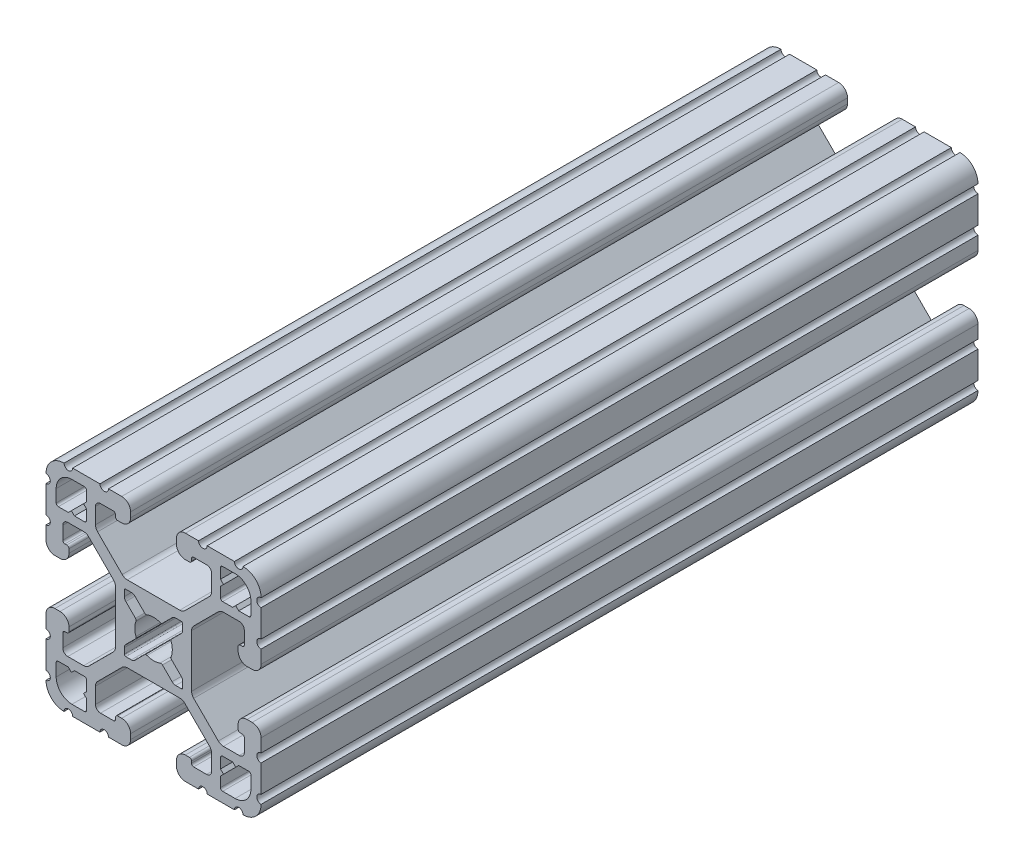
from build123d import *

# Parameters (mm, degrees)
BOSS_EXTRUDE1_DEPTH = 127


with BuildPart() as part:
    # Sketch1 → Boss-Extrude1 (new body)
    with BuildSketch(Plane(origin=(0, 0, -2322.576), x_dir=(-1, 0, 0), z_dir=(0, 0, -1))):
        with BuildLine():
            Line((19.05, -14.325600033), (19.05, -9.4996))
            ThreePointArc((19.05, -9.4996), (18.288, -8.7376), (19.05, -7.9756))
            Line((19.05, -7.9756), (19.05, -5.6388))
            ThreePointArc((19.05, -5.6388), (18.588751759, -4.525248241), (17.4752, -4.064))
            Line((17.4752, -4.064), (16.5608, -4.064))
            ThreePointArc((16.5608, -4.064), (15.447248241, -4.525248241), (14.986, -5.6388))
            Line((14.986, -5.6388), (14.986, -6.350014224))
            ThreePointArc((14.986, -6.350014224), (15.097592316, -6.619421908), (15.367, -6.731014224))
            Line((15.367, -6.731014224), (15.6972, -6.731014224))
            ThreePointArc((15.6972, -6.731014224), (15.966607684, -6.84260654), (16.0782, -7.112014224))
            Line((16.0782, -7.112014224), (16.0782, -9.398014224))
            ThreePointArc((16.0782, -9.398014224), (15.817817928, -10.026632152), (15.1892, -10.287014224))
            Line((15.1892, -10.287014224), (12.375630013, -10.287014224))
            ThreePointArc((12.375630013, -10.287014224), (11.889622054, -10.19034123), (11.477604401, -9.915039836))
            Line((11.477604401, -9.915039836), (7.115699788, -5.553135223))
            ThreePointArc((7.115699788, -5.553135223), (6.840398394, -5.14111757), (6.7437254, -4.655109611))
            Line((6.7437254, -4.655109611), (6.7437254, 4.655109611))
            ThreePointArc((6.7437254, 4.655109611), (6.840398394, 5.14111757), (7.115699788, 5.553135223))
            Line((7.115699788, 5.553135223), (11.477604401, 9.915039836))
            ThreePointArc((11.477604401, 9.915039836), (11.889622054, 10.19034123), (12.375630013, 10.287014224))
            Line((12.375630013, 10.287014224), (15.1892, 10.287014224))
            ThreePointArc((15.1892, 10.287014224), (15.817817928, 10.026632152), (16.0782, 9.398014224))
            Line((16.0782, 9.398014224), (16.0782, 7.112014224))
            ThreePointArc((16.0782, 7.112014224), (15.966607684, 6.84260654), (15.6972, 6.731014224))
            Line((15.6972, 6.731014224), (15.367, 6.731014224))
            ThreePointArc((15.367, 6.731014224), (15.097592316, 6.619421908), (14.986, 6.350014224))
            Line((14.986, 6.350014224), (14.986, 5.6388))
            ThreePointArc((14.986, 5.6388), (15.447248241, 4.525248241), (16.5608, 4.064))
            Line((16.5608, 4.064), (17.4752, 4.064))
            ThreePointArc((17.4752, 4.064), (18.588751759, 4.525248241), (19.05, 5.6388))
            Line((19.05, 5.6388), (19.05, 7.9756))
            ThreePointArc((19.05, 7.9756), (18.288, 8.7376), (19.05, 9.4996))
            Line((19.05, 9.4996), (19.05, 14.325599984))
            ThreePointArc((19.05, 14.325599984), (18.287999986, 15.087549208), (19.049898416, 15.849600009))
            ThreePointArc((19.049898416, 15.849600009), (18.120064036, 18.120064058), (15.849599977, 19.049898414))
            ThreePointArc((15.849599977, 19.049898414), (15.0875492, 18.288000035), (14.325600017, 19.050000016))
            Line((14.325600017, 19.050000016), (9.499600001, 19.050000016))
            ThreePointArc((9.499600001, 19.050000016), (8.737600001, 18.288000016), (7.975600001, 19.050000016))
            Line((7.975600001, 19.050000016), (5.638800016, 19.050000016))
            ThreePointArc((5.638800016, 19.050000016), (4.525248257, 18.588751775), (4.064000016, 17.475200016))
            Line((4.064000016, 17.475200016), (4.064000016, 16.5608))
            ThreePointArc((4.064000016, 16.5608), (4.525248257, 15.447248241), (5.638800016, 14.986))
            Line((5.638800016, 14.986), (6.350014224, 14.986))
            ThreePointArc((6.350014224, 14.986), (6.619421908, 15.097592316), (6.731014224, 15.367))
            Line((6.731014224, 15.367), (6.731014224, 15.6972))
            ThreePointArc((6.731014224, 15.6972), (6.84260654, 15.966607684), (7.112014224, 16.0782))
            Line((7.112014224, 16.0782), (9.398014224, 16.0782))
            ThreePointArc((9.398014224, 16.0782), (10.026632152, 15.817817928), (10.287014224, 15.1892))
            Line((10.287014224, 15.1892), (10.287014224, 12.375630013))
            ThreePointArc((10.287014224, 12.375630013), (10.19034123, 11.889622054), (9.915039836, 11.477604401))
            Line((9.915039836, 11.477604401), (5.553135223, 7.115699788))
            ThreePointArc((5.553135223, 7.115699788), (5.14111757, 6.840398394), (4.655109611, 6.7437254))
            Line((4.655109611, 6.7437254), (-4.655109611, 6.7437254))
            ThreePointArc((-4.655109611, 6.7437254), (-5.14111757, 6.840398394), (-5.553135223, 7.115699788))
            Line((-5.553135223, 7.115699788), (-9.915039836, 11.477604401))
            ThreePointArc((-9.915039836, 11.477604401), (-10.19034123, 11.889622054), (-10.287014224, 12.375630013))
            Line((-10.287014224, 12.375630013), (-10.287014224, 15.1892))
            ThreePointArc((-10.287014224, 15.1892), (-10.026632152, 15.817817928), (-9.398014224, 16.0782))
            Line((-9.398014224, 16.0782), (-7.112014224, 16.0782))
            ThreePointArc((-7.112014224, 16.0782), (-6.84260654, 15.966607684), (-6.731014224, 15.6972))
            Line((-6.731014224, 15.6972), (-6.731014224, 15.367))
            ThreePointArc((-6.731014224, 15.367), (-6.619421908, 15.097592316), (-6.350014224, 14.986))
            Line((-6.350014224, 14.986), (-5.638799984, 14.986))
            ThreePointArc((-5.638799984, 14.986), (-4.525248225, 15.447248241), (-4.063999984, 16.5608))
            Line((-4.063999984, 16.5608), (-4.063999984, 17.475200016))
            ThreePointArc((-4.063999984, 17.475200016), (-4.525248225, 18.588751775), (-5.638799984, 19.050000016))
            Line((-5.638799984, 19.050000016), (-7.975599999, 19.050000016))
            ThreePointArc((-7.975599999, 19.050000016), (-8.737599999, 18.288000016), (-9.499599999, 19.050000016))
            Line((-9.499599999, 19.050000016), (-14.325599999, 19.050000016))
            ThreePointArc((-14.325599999, 19.050000016), (-15.087549199, 18.288000018), (-15.849599993, 19.049898416))
            ThreePointArc((-15.849599993, 19.049898416), (-18.120064042, 18.120064036), (-19.049898398, 15.849599976))
            ThreePointArc((-19.049898398, 15.849599976), (-18.288000019, 15.087549199), (-19.05, 14.325600017))
            Line((-19.05, 14.325600017), (-19.05, 9.4996))
            ThreePointArc((-19.05, 9.4996), (-18.288, 8.7376), (-19.05, 7.9756))
            Line((-19.05, 7.9756), (-19.05, 5.6388))
            ThreePointArc((-19.05, 5.6388), (-18.588751759, 4.525248241), (-17.4752, 4.064))
            Line((-17.4752, 4.064), (-16.5608, 4.064))
            ThreePointArc((-16.5608, 4.064), (-15.447248241, 4.525248241), (-14.986, 5.6388))
            Line((-14.986, 5.6388), (-14.986, 6.350014224))
            ThreePointArc((-14.986, 6.350014224), (-15.097592316, 6.619421908), (-15.367, 6.731014224))
            Line((-15.367, 6.731014224), (-15.6972, 6.731014224))
            ThreePointArc((-15.6972, 6.731014224), (-15.966607684, 6.84260654), (-16.0782, 7.112014224))
            Line((-16.0782, 7.112014224), (-16.0782, 9.398014224))
            ThreePointArc((-16.0782, 9.398014224), (-15.817817928, 10.026632152), (-15.1892, 10.287014224))
            Line((-15.1892, 10.287014224), (-12.375630013, 10.287014224))
            ThreePointArc((-12.375630013, 10.287014224), (-11.889622054, 10.19034123), (-11.477604401, 9.915039836))
            Line((-11.477604401, 9.915039836), (-7.115699788, 5.553135223))
            ThreePointArc((-7.115699788, 5.553135223), (-6.840398394, 5.14111757), (-6.7437254, 4.655109611))
            Line((-6.7437254, 4.655109611), (-6.7437254, -4.655109611))
            ThreePointArc((-6.7437254, -4.655109611), (-6.840398394, -5.14111757), (-7.115699788, -5.553135223))
            Line((-7.115699788, -5.553135223), (-11.477604401, -9.915039836))
            ThreePointArc((-11.477604401, -9.915039836), (-11.889622054, -10.19034123), (-12.375630013, -10.287014224))
            Line((-12.375630013, -10.287014224), (-15.1892, -10.287014224))
            ThreePointArc((-15.1892, -10.287014224), (-15.817817928, -10.026632152), (-16.0782, -9.398014224))
            Line((-16.0782, -9.398014224), (-16.0782, -7.112014224))
            ThreePointArc((-16.0782, -7.112014224), (-15.966607684, -6.84260654), (-15.6972, -6.731014224))
            Line((-15.6972, -6.731014224), (-15.367, -6.731014224))
            ThreePointArc((-15.367, -6.731014224), (-15.097592316, -6.619421908), (-14.986, -6.350014224))
            Line((-14.986, -6.350014224), (-14.986, -5.6388))
            ThreePointArc((-14.986, -5.6388), (-15.447248241, -4.525248241), (-16.5608, -4.064))
            Line((-16.5608, -4.064), (-17.4752, -4.064))
            ThreePointArc((-17.4752, -4.064), (-18.588751759, -4.525248241), (-19.05, -5.6388))
            Line((-19.05, -5.6388), (-19.05, -7.9756))
            ThreePointArc((-19.05, -7.9756), (-18.288, -8.7376), (-19.05, -9.4996))
            Line((-19.05, -9.4996), (-19.05, -14.3256))
            ThreePointArc((-19.05, -14.3256), (-18.288000002, -15.0875492), (-19.0498984, -15.849599993))
            ThreePointArc((-19.0498984, -15.849599993), (-18.120064019, -18.120064043), (-15.84959996, -19.049898399))
            ThreePointArc((-15.84959996, -19.049898399), (-15.087549183, -18.288000019), (-14.325600001, -19.050000001))
            Line((-14.325600001, -19.050000001), (-9.499599984, -19.050000001))
            ThreePointArc((-9.499599984, -19.050000001), (-8.737599984, -18.288000001), (-7.975599984, -19.050000001))
            Line((-7.975599984, -19.050000001), (-5.638799984, -19.050000001))
            ThreePointArc((-5.638799984, -19.050000001), (-4.525248225, -18.58875176), (-4.063999984, -17.475200001))
            Line((-4.063999984, -17.475200001), (-4.063999984, -16.5608))
            ThreePointArc((-4.063999984, -16.5608), (-4.525248225, -15.447248241), (-5.638799984, -14.986))
            Line((-5.638799984, -14.986), (-6.350014224, -14.986))
            ThreePointArc((-6.350014224, -14.986), (-6.619421908, -15.097592316), (-6.731014224, -15.367))
            Line((-6.731014224, -15.367), (-6.731014224, -15.6972))
            ThreePointArc((-6.731014224, -15.6972), (-6.84260654, -15.966607684), (-7.112014224, -16.0782))
            Line((-7.112014224, -16.0782), (-9.398014224, -16.0782))
            ThreePointArc((-9.398014224, -16.0782), (-10.026632152, -15.817817928), (-10.287014224, -15.1892))
            Line((-10.287014224, -15.1892), (-10.287014224, -12.375630013))
            ThreePointArc((-10.287014224, -12.375630013), (-10.19034123, -11.889622054), (-9.915039836, -11.477604401))
            Line((-9.915039836, -11.477604401), (-5.553135223, -7.115699788))
            ThreePointArc((-5.553135223, -7.115699788), (-5.14111757, -6.840398394), (-4.655109611, -6.7437254))
            Line((-4.655109611, -6.7437254), (4.655109611, -6.7437254))
            ThreePointArc((4.655109611, -6.7437254), (5.14111757, -6.840398394), (5.553135223, -7.115699788))
            Line((5.553135223, -7.115699788), (9.915039836, -11.477604401))
            ThreePointArc((9.915039836, -11.477604401), (10.19034123, -11.889622054), (10.287014224, -12.375630013))
            Line((10.287014224, -12.375630013), (10.287014224, -15.1892))
            ThreePointArc((10.287014224, -15.1892), (10.026632152, -15.817817928), (9.398014224, -16.0782))
            Line((9.398014224, -16.0782), (7.112014224, -16.0782))
            ThreePointArc((7.112014224, -16.0782), (6.84260654, -15.966607684), (6.731014224, -15.6972))
            Line((6.731014224, -15.6972), (6.731014224, -15.367))
            ThreePointArc((6.731014224, -15.367), (6.619421908, -15.097592316), (6.350014224, -14.986))
            Line((6.350014224, -14.986), (5.638800016, -14.986))
            ThreePointArc((5.638800016, -14.986), (4.525248257, -15.447248241), (4.064000016, -16.5608))
            Line((4.064000016, -16.5608), (4.064000016, -17.475200001))
            ThreePointArc((4.064000016, -17.475200001), (4.525248257, -18.58875176), (5.638800016, -19.050000001))
            Line((5.638800016, -19.050000001), (7.975600016, -19.050000001))
            ThreePointArc((7.975600016, -19.050000001), (8.737600016, -18.288000001), (9.499600016, -19.050000001))
            Line((9.499600016, -19.050000001), (14.325600016, -19.050000001))
            ThreePointArc((14.325600016, -19.050000001), (15.087549216, -18.288000002), (15.849600009, -19.0498984))
            ThreePointArc((15.849600009, -19.0498984), (18.120064059, -18.12006402), (19.049898415, -15.849599961))
            ThreePointArc((19.049898415, -15.849599961), (18.288000034, -15.087549207), (19.05, -14.325600033))
        make_face()
        with BuildLine():
            Line((17.246614224, 14.452614224), (17.246614224, 12.242814224))
            ThreePointArc((17.246614224, 12.242814224), (17.135021908, 11.97340654), (16.865614224, 11.861814224))
            Line((16.865614224, 11.861814224), (15.092694224, 11.861814224))
            Line((15.092694224, 11.861814224), (14.554214224, 12.400294224))
            Line((14.554214224, 12.400294224), (14.015734224, 11.861814224))
            Line((14.015734224, 11.861814224), (12.242814224, 11.861814224))
            ThreePointArc((12.242814224, 11.861814224), (11.97340654, 11.97340654), (11.861814224, 12.242814224))
            Line((11.861814224, 12.242814224), (11.861814224, 14.015734224))
            Line((11.861814224, 14.015734224), (12.400294224, 14.554214224))
            Line((12.400294224, 14.554214224), (11.861814224, 15.092694224))
            Line((11.861814224, 15.092694224), (11.861814224, 16.865614224))
            ThreePointArc((11.861814224, 16.865614224), (11.97340654, 17.135021908), (12.242814224, 17.246614224))
            Line((12.242814224, 17.246614224), (14.452614224, 17.246614224))
            ThreePointArc((14.452614224, 17.246614224), (16.428270571, 16.428270571), (17.246614224, 14.452614224))
        make_face(mode=Mode.SUBTRACT)
        with BuildLine():
            Line((17.246614224, -12.242814224), (17.246614224, -14.452614224))
            ThreePointArc((17.246614224, -14.452614224), (16.428270571, -16.428270571), (14.452614224, -17.246614224))
            Line((14.452614224, -17.246614224), (12.242814224, -17.246614224))
            ThreePointArc((12.242814224, -17.246614224), (11.97340654, -17.135021908), (11.861814224, -16.865614224))
            Line((11.861814224, -16.865614224), (11.861814224, -15.092694224))
            Line((11.861814224, -15.092694224), (12.400294224, -14.554214224))
            Line((12.400294224, -14.554214224), (11.861814224, -14.015734224))
            Line((11.861814224, -14.015734224), (11.861814224, -12.242814224))
            ThreePointArc((11.861814224, -12.242814224), (11.97340654, -11.97340654), (12.242814224, -11.861814224))
            Line((12.242814224, -11.861814224), (14.015734224, -11.861814224))
            Line((14.015734224, -11.861814224), (14.554214224, -12.400294224))
            Line((14.554214224, -12.400294224), (15.092694224, -11.861814224))
            Line((15.092694224, -11.861814224), (16.865614224, -11.861814224))
            ThreePointArc((16.865614224, -11.861814224), (17.135021908, -11.97340654), (17.246614224, -12.242814224))
        make_face(mode=Mode.SUBTRACT)
        with BuildLine():
            Line((5.1689, -3.920689755), (5.1689, -4.9149))
            ThreePointArc((5.1689, -4.9149), (5.094505122, -5.094505122), (4.9149, -5.1689))
            Line((4.9149, -5.1689), (3.920689755, -5.1689))
            ThreePointArc((3.920689755, -5.1689), (3.580484184, -5.101228904), (3.292071827, -4.908517928))
            Line((3.292071827, -4.908517928), (1.582347442, -3.198793543))
            ThreePointArc((1.582347442, -3.198793543), (1.393016011, -3.095711236), (1.178048687, -3.111879183))
            ThreePointArc((1.178048687, -3.111879183), (0, -3.3274), (-1.178048687, -3.111879183))
            ThreePointArc((-1.178048687, -3.111879183), (-1.393016011, -3.095711236), (-1.582347442, -3.198793543))
            Line((-1.582347442, -3.198793543), (-3.292071827, -4.908517928))
            ThreePointArc((-3.292071827, -4.908517928), (-3.580484184, -5.101228904), (-3.920689755, -5.1689))
            Line((-3.920689755, -5.1689), (-4.9149, -5.1689))
            ThreePointArc((-4.9149, -5.1689), (-5.094505122, -5.094505122), (-5.1689, -4.9149))
            Line((-5.1689, -4.9149), (-5.1689, -3.920689755))
            ThreePointArc((-5.1689, -3.920689755), (-5.101228904, -3.580484184), (-4.908517928, -3.292071827))
            Line((-4.908517928, -3.292071827), (-3.198793543, -1.582347442))
            ThreePointArc((-3.198793543, -1.582347442), (-3.095711236, -1.393016011), (-3.111879183, -1.178048687))
            ThreePointArc((-3.111879183, -1.178048687), (-3.3274, 0), (-3.111879183, 1.178048687))
            ThreePointArc((-3.111879183, 1.178048687), (-3.095711236, 1.393016011), (-3.198793543, 1.582347442))
            Line((-3.198793543, 1.582347442), (-4.908517928, 3.292071827))
            ThreePointArc((-4.908517928, 3.292071827), (-5.101228904, 3.580484184), (-5.1689, 3.920689755))
            Line((-5.1689, 3.920689755), (-5.1689, 4.9149))
            ThreePointArc((-5.1689, 4.9149), (-5.094505122, 5.094505122), (-4.9149, 5.1689))
            Line((-4.9149, 5.1689), (-3.920689755, 5.1689))
            ThreePointArc((-3.920689755, 5.1689), (-3.580484184, 5.101228904), (-3.292071827, 4.908517928))
            Line((-3.292071827, 4.908517928), (-1.582347442, 3.198793543))
            ThreePointArc((-1.582347442, 3.198793543), (-1.393016011, 3.095711236), (-1.178048687, 3.111879183))
            ThreePointArc((-1.178048687, 3.111879183), (0, 3.3274), (1.178048687, 3.111879183))
            ThreePointArc((1.178048687, 3.111879183), (1.393016011, 3.095711236), (1.582347442, 3.198793543))
            Line((1.582347442, 3.198793543), (3.292071827, 4.908517928))
            ThreePointArc((3.292071827, 4.908517928), (3.580484184, 5.101228904), (3.920689755, 5.1689))
            Line((3.920689755, 5.1689), (4.9149, 5.1689))
            ThreePointArc((4.9149, 5.1689), (5.094505122, 5.094505122), (5.1689, 4.9149))
            Line((5.1689, 4.9149), (5.1689, 3.920689755))
            ThreePointArc((5.1689, 3.920689755), (5.101228904, 3.580484184), (4.908517928, 3.292071827))
            Line((4.908517928, 3.292071827), (3.198793543, 1.582347442))
            ThreePointArc((3.198793543, 1.582347442), (3.095711236, 1.393016011), (3.111879183, 1.178048687))
            ThreePointArc((3.111879183, 1.178048687), (3.3274, 0), (3.111879183, -1.178048687))
            ThreePointArc((3.111879183, -1.178048687), (3.095711236, -1.393016011), (3.198793543, -1.582347442))
            Line((3.198793543, -1.582347442), (4.908517928, -3.292071827))
            ThreePointArc((4.908517928, -3.292071827), (5.101228904, -3.580484184), (5.1689, -3.920689755))
        make_face(mode=Mode.SUBTRACT)
        with BuildLine():
            Line((-11.861814224, -12.242814224), (-11.861814224, -14.015734224))
            Line((-11.861814224, -14.015734224), (-12.400294224, -14.554214224))
            Line((-12.400294224, -14.554214224), (-11.861814224, -15.092694224))
            Line((-11.861814224, -15.092694224), (-11.861814224, -16.865614224))
            ThreePointArc((-11.861814224, -16.865614224), (-11.97340654, -17.135021908), (-12.242814224, -17.246614224))
            Line((-12.242814224, -17.246614224), (-14.452614224, -17.246614224))
            ThreePointArc((-14.452614224, -17.246614224), (-16.428270571, -16.428270571), (-17.246614224, -14.452614224))
            Line((-17.246614224, -14.452614224), (-17.246614224, -12.242814224))
            ThreePointArc((-17.246614224, -12.242814224), (-17.135021908, -11.97340654), (-16.865614224, -11.861814224))
            Line((-16.865614224, -11.861814224), (-15.092694224, -11.861814224))
            Line((-15.092694224, -11.861814224), (-14.554214224, -12.400294224))
            Line((-14.554214224, -12.400294224), (-14.015734224, -11.861814224))
            Line((-14.015734224, -11.861814224), (-12.242814224, -11.861814224))
            ThreePointArc((-12.242814224, -11.861814224), (-11.97340654, -11.97340654), (-11.861814224, -12.242814224))
        make_face(mode=Mode.SUBTRACT)
        with BuildLine():
            Line((-11.861814224, 16.865614224), (-11.861814224, 15.092694224))
            Line((-11.861814224, 15.092694224), (-12.400294224, 14.554214224))
            Line((-12.400294224, 14.554214224), (-11.861814224, 14.015734224))
            Line((-11.861814224, 14.015734224), (-11.861814224, 12.242814224))
            ThreePointArc((-11.861814224, 12.242814224), (-11.97340654, 11.97340654), (-12.242814224, 11.861814224))
            Line((-12.242814224, 11.861814224), (-14.015734224, 11.861814224))
            Line((-14.015734224, 11.861814224), (-14.554214224, 12.400294224))
            Line((-14.554214224, 12.400294224), (-15.092694224, 11.861814224))
            Line((-15.092694224, 11.861814224), (-16.865614224, 11.861814224))
            ThreePointArc((-16.865614224, 11.861814224), (-17.135021908, 11.97340654), (-17.246614224, 12.242814224))
            Line((-17.246614224, 12.242814224), (-17.246614224, 14.452614224))
            ThreePointArc((-17.246614224, 14.452614224), (-16.428270571, 16.428270571), (-14.452614224, 17.246614224))
            Line((-14.452614224, 17.246614224), (-12.242814224, 17.246614224))
            ThreePointArc((-12.242814224, 17.246614224), (-11.97340654, 17.135021908), (-11.861814224, 16.865614224))
        make_face(mode=Mode.SUBTRACT)
    extrude(amount=-BOSS_EXTRUDE1_DEPTH)


solid = part.part
